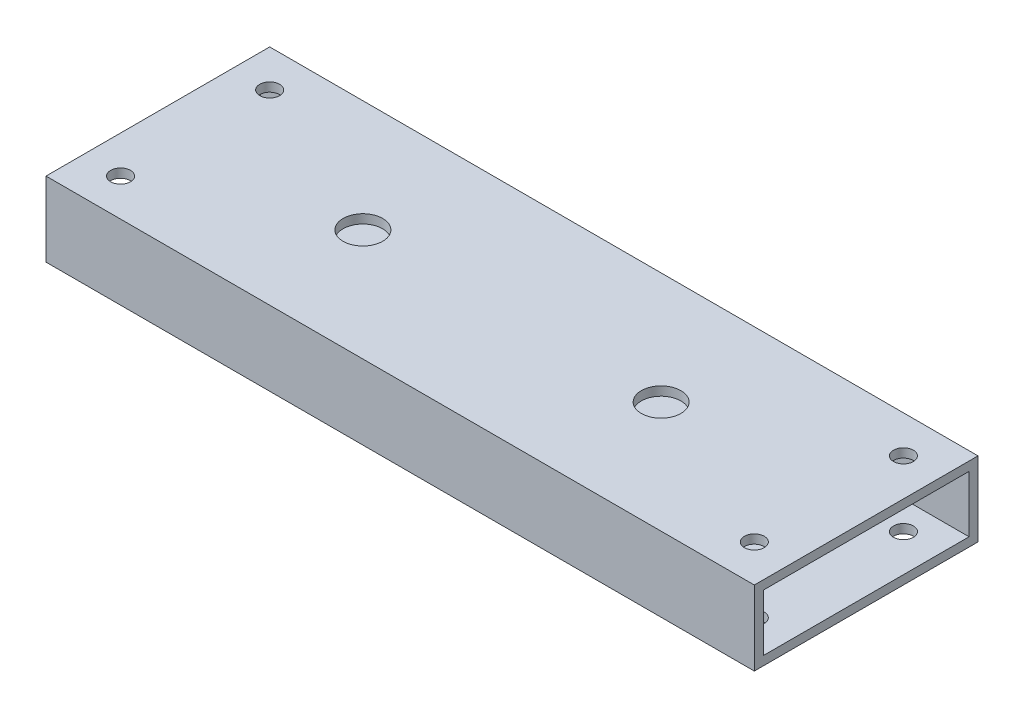
from build123d import *

# Parameters (mm, degrees)
SKETCH11_W                               = 76.2
SKETCH11_H                               = 25.4
SKETCH11_W_2                             = 70.104
SKETCH11_H_2                             = 19.304
RECTANGULAR_TUBE_1_5_X_3_X_125_1_DEPTH   = 241.3
CBORE_FOR_1_2_HEX_HEAD_BOLT1_D           = 13.49248
CBORE_FOR_1_2_HEX_HEAD_BOLT1_CBORE_D     = 28.575
CBORE_FOR_1_2_HEX_HEAD_BOLT1_CBORE_DEPTH = 3.175
F_1_4_CLEARANCE_HOLE1_D                  = 6.7564


with BuildPart() as part:
    # Sketch11 → Rectangular tube 1.5 X 3 X .125(1) (new body)
    with BuildSketch(Plane.ZY.offset(-120.65)):
        Rectangle(SKETCH11_W, SKETCH11_H)
        Rectangle(SKETCH11_W_2, SKETCH11_H_2, mode=Mode.SUBTRACT)
    extrude(amount=RECTANGULAR_TUBE_1_5_X_3_X_125_1_DEPTH)

    # CBORE for 1/2 Hex Head Bolt1 (through all)
    with Locations(Plane(origin=(0, -12.7, 0), x_dir=(-1, 0, 0), z_dir=(0, -1, 0))):
        with Locations((50.8, 0), (-50.8, 0)):
            CounterBoreHole(CBORE_FOR_1_2_HEX_HEAD_BOLT1_D / 2, CBORE_FOR_1_2_HEX_HEAD_BOLT1_CBORE_D / 2, CBORE_FOR_1_2_HEX_HEAD_BOLT1_CBORE_DEPTH)

    # 1/4 Clearance Hole1 (through all)
    with Locations(Plane(origin=(0, -12.7, 0), x_dir=(-1, 0, 0), z_dir=(0, -1, 0))):
        with Locations((107.95, -25.4), (107.95, 25.4), (-107.95, 25.4), (-107.95, -25.4)):
            Hole(F_1_4_CLEARANCE_HOLE1_D / 2)


solid = part.part
